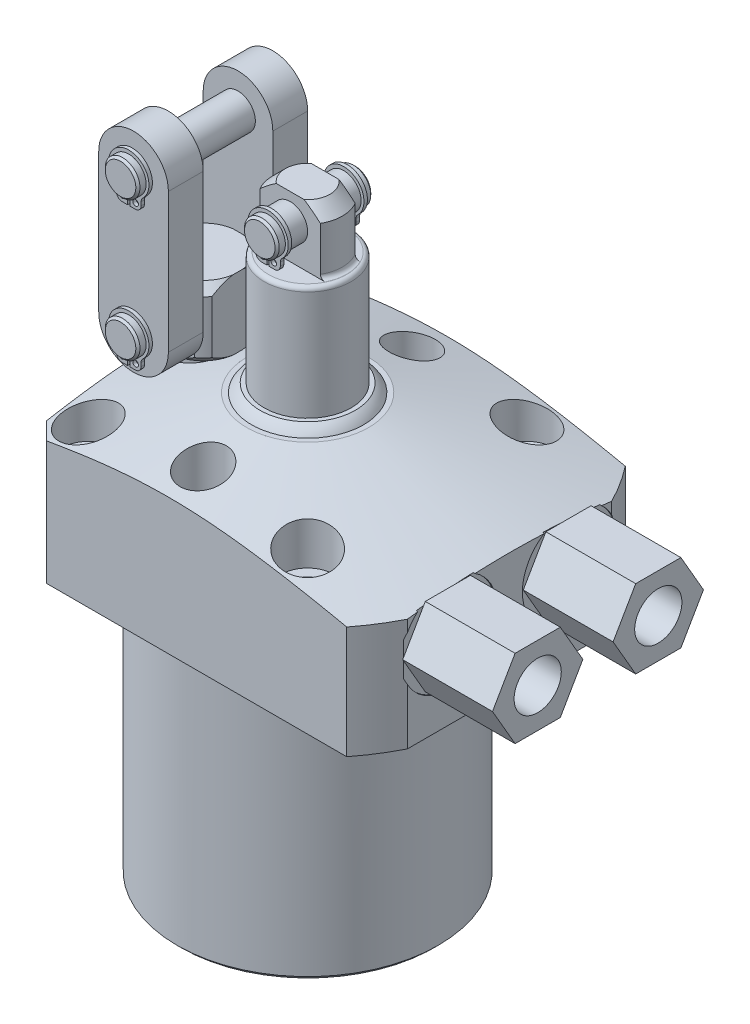
from build123d import *

# Parameters (mm, degrees)
SKETCH3_OUTSIDE_W          = 112.432
SKETCH3_OUTSIDE_H          = 112.432
SKETCH3_OUTSIDE_W_2        = 62.23
SKETCH3_OUTSIDE_H_2        = 50.8
CUT_EXTRUDE9_DEPTH         = 76.2
CHAMFER8_SIZE              = 3.175
CHAMFER5_SIZE              = 0.762
HOLE1_D                    = 5.5626
HOLE1_DEPTH                = 28.575
HOLE1_CBORE_D              = 9.525
HOLE1_CBORE_DEPTH          = 11.0998
SKETCH34_R                 = 4.2164
CUT_EXTRUDE10_DEPTH        = 12.7
EXTRUDE14_DEPTH            = 16.383
HOLE2_D                    = 8.6106
HOLE2_DEPTH                = 6.7056
SKETCH33_R                 = 0.889
CUT_EXTRUDE7_DEPTH         = 11.0998
FILLET4_R                  = 0.762
SKETCH29_R                 = 3.16865
EXTRUDE11_DEPTH            = 8.7249
EXTRUDE2_START             = -1.4986
SKETCH16_R                 = 0.5207
EXTRUDE2_DEPTH             = 0.635
CHAMFER6_SIZE              = 0.381
CUT_EXTRUDE11_DEPTH        = 12.7
SKETCH30_R                 = 3.16865
EXTRUDE12_DEPTH            = 15.0749
EXTRUDE4_START             = -1.4986
SKETCH19_R                 = 0.5207
EXTRUDE4_DEPTH             = 0.635
EXTRUDE13_DEPTH            = 6.35
CHAMFER7_SIZE              = 0.381
LPATTERN2_COUNT            = 2
LPATTERN2_PITCH            = 25.4
LPATTERN2_START            = -1.4986
LPATTERN2_COPY_1_SKETCH_R  = 0.5207
LPATTERN2_COPY_1_DEPTH     = 0.635
CHAMFER7_OF_LPATTERN2_SIZE = 0.381


with BuildPart() as part:
    # Sketch28 → Revolve7 (revolve)
    with BuildSketch(Plane.XY, mode=Mode.PRIVATE) as revolve7_sk:
        Polygon((-11.1125, 28.575), (-41.275, 20.492982483), (-41.275, 0), (-23.8125, 0), (-23.8125, -47.625), (0, -47.625), (0, 28.575), align=None)
    revolve(revolve7_sk.sketch.rotate(Axis((0, 0, 0), (0, 1, 0)), 270), axis=Axis((0, 0, 0), (0, 1, 0)))  # turned: the seam where the file's is

    # Sketch3 outside → Cut-Extrude9 (cut)
    with BuildSketch(Plane(origin=(0, 28.575, 0), x_dir=(-1, 0, 0), z_dir=(0, 1, 0))):
        Rectangle(SKETCH3_OUTSIDE_W, SKETCH3_OUTSIDE_H)
        with Locations((-5.715, 0)):
            Rectangle(SKETCH3_OUTSIDE_W_2, SKETCH3_OUTSIDE_H_2, mode=Mode.SUBTRACT)
    extrude(amount=-CUT_EXTRUDE9_DEPTH, mode=Mode.SUBTRACT)

    # Chamfer8
    chamfer8_edges = [part.edges().sort_by_distance(p)[0] for p in [
        (-25.4, 10.96378795, -25.4),
        (-25.4, 10.96378795, 25.4),
    ]]
    chamfer(chamfer8_edges, length=CHAMFER8_SIZE)

    # Chamfer5
    chamfer5_edges = [part.edges().sort_by_distance(p)[0] for p in [
        (0, -47.625, 23.8125),
    ]]
    chamfer(chamfer5_edges, length=CHAMFER5_SIZE)

    # Hole1
    with Locations(Plane(origin=(0, 28.575, 0), x_dir=(-1, 0, 0), z_dir=(0, 1, 0))):
        with Locations((-20.0025, -20.0025), (-20.0025, 20.0025), (20.0025, -20.0025), (20.0025, 20.0025)):
            CounterBoreHole(HOLE1_D / 2, HOLE1_CBORE_D / 2, HOLE1_CBORE_DEPTH, depth=HOLE1_DEPTH)

    # Sketch34 → Cut-Extrude10 (cut)
    with BuildSketch(Plane(origin=(0, 28.575, 0), x_dir=(1, 0, 0), z_dir=(0, 1, 0))):
        with Locations(Location((0, 19.05, 0), (0, 0, 270))):  # turned: the seam where the file's is
            Circle(SKETCH34_R)
        with Locations(Location((0, -19.05, 0), (0, 0, 133.869906741))):  # turned: the seam where the file's is
            Circle(SKETCH34_R)
        with Locations(Location((-19.05, 0, 0), (0, 0, 270))):  # turned: the seam where the file's is
            Circle(SKETCH34_R)
    extrude(amount=-CUT_EXTRUDE10_DEPTH, mode=Mode.SUBTRACT)

    # S2D0007 → Cut-Revolve2 (revolve, cut)
    with BuildSketch(Plane.XZ.offset(-14.2748)):
        Polygon((36.83, -10.9982), (36.83, -19.6596), (36.576, -19.6596), (36.576, -15.57655), (34.5059, -15.136536662), (33.821963338, -14.4526), (24.384, -14.4526), (22.308387078, -10.9982), align=None)
    cut_revolve2 = revolve(axis=Axis((-11.746808274, 14.2748, -10.9982), (-1, 0, 0)), mode=Mode.SUBTRACT)

    # Sketch6 → Cut-Revolve3 (revolve, cut)
    with BuildSketch(Plane.XY.offset(-10.9982), mode=Mode.PRIVATE) as cut_revolve3_sk:
        with BuildLine():
            Line((35.66795, 0), (35.66795, 1.4478))
            Line((35.66795, 1.4478), (32.60745581, 1.4478))
            ThreePointArc((32.60745581, 1.4478), (31.925854622, 0.917608896), (31.1404, 0.5588))
            Line((31.1404, 0.5588), (29.9974, 0.5588))
            Line((29.9974, 0.5588), (29.9974, 0))
            Line((29.9974, 0), (35.66795, 0))
        make_face()
    cut_revolve3 = revolve(cut_revolve3_sk.sketch.rotate(Axis((29.9974, -21.049171587, -10.9982), (0, 1, 0)), 90), axis=Axis((29.9974, -21.049171587, -10.9982), (0, 1, 0)), mode=Mode.SUBTRACT)  # turned: the seam where the file's is

    # Sketch39 → Extrude14 (add)
    with BuildSketch(Plane(origin=(36.576, 0, 0), x_dir=(0, 0, -1), z_dir=(1, 0, 0))):
        Polygon((19.239759623, 14.2748), (15.118979811, 21.4122), (6.877420189, 21.4122), (2.756640377, 14.2748), (6.877420189, 7.1374), (15.118979811, 7.1374), align=None)
    extrude14 = extrude(amount=EXTRUDE14_DEPTH)

    # Hole2
    with Locations(Plane(origin=(52.959, 0, 0), x_dir=(0, 0, -1), z_dir=(1, 0, 0))):
        with Locations((10.9982, 14.2748)):
            hole2 = Hole(HOLE2_D / 2, depth=HOLE2_DEPTH)

    # Mirror6: Cut-Revolve2, Cut-Revolve3, Extrude14, Hole2 across plane
    add(cut_revolve2.mirror(Plane.XY), mode=Mode.SUBTRACT)
    add(cut_revolve3.mirror(Plane.XY), mode=Mode.SUBTRACT)
    add(extrude14.mirror(Plane.XY))
    add(hole2.mirror(Plane.XY), mode=Mode.SUBTRACT)

    # Sketch12 → Revolve2 (revolve)
    with BuildSketch(Plane(origin=(0, 0, 0), x_dir=(-1, 0, 0), z_dir=(0, 0, -1)), mode=Mode.PRIVATE) as revolve2_sk:
        with BuildLine():
            Line((0, 28.575), (0, 30.099))
            Line((0, 30.099), (8.6995, 30.099))
            ThreePointArc((8.6995, 30.099), (9.549082922, 29.424582922), (10.2235, 28.575))
            Line((10.2235, 28.575), (0, 28.575))
        make_face()
    revolve(revolve2_sk.sketch.rotate(Axis((0, 22.10562, 0), (0, 1, 0)), 270), axis=Axis((0, 22.10562, 0), (0, 1, 0)))  # turned: the seam where the file's is

    # Sketch13 → Revolve3 (revolve)
    with BuildSketch(Plane.XY, mode=Mode.PRIVATE) as revolve3_sk:
        Polygon((0, 30.099), (0, 61.8998), (4.064, 61.8998), (6.35, 59.6138), (6.35, 50.8), (7.93115, 50.8), (7.93115, 30.099), align=None)
    revolve(revolve3_sk.sketch.rotate(Axis((0, 23.02637, 0), (0, 1, 0)), 90), axis=Axis((0, 23.02637, 0), (0, 1, 0)))  # turned: the seam where the file's is

    # Sketch14 → Cut-Extrude7 (cut)
    with BuildSketch(Plane(origin=(0, 61.8998, 0), x_dir=(-1, 0, 0), z_dir=(0, 1, 0))):
        with BuildLine():
            Line((-5.499261314, 3.175), (5.499261314, 3.175))
            ThreePointArc((5.499261314, 3.175), (0, 6.35), (-5.499261314, 3.175))
        make_face()
        with BuildLine():
            Line((5.499261314, -3.175), (-5.499261314, -3.175))
            ThreePointArc((-5.499261314, -3.175), (0, -6.35), (5.499261314, -3.175))
        make_face()
    extrude(amount=-CUT_EXTRUDE7_DEPTH, mode=Mode.SUBTRACT)

    # Fillet4
    fillet4_edges = [part.edges().sort_by_distance(p)[0] for p in [
        (0, 50.8, 7.93115),
        (-6.35, 50.8, 0),
        (6.35, 50.8, 0),
    ]]
    fillet(fillet4_edges, radius=FILLET4_R)

    # Sketch29 → Extrude11 (add, symmetric)
    with BuildSketch(Plane.XY):
        with Locations((0, 57.15)):
            Circle(SKETCH29_R)
    extrude(amount=EXTRUDE11_DEPTH, both=True)

    # Sketch16 → Extrude2 (add)
    with BuildSketch(Plane(origin=(0, 52.3748, 8.7249), x_dir=(1, 0, 0), z_dir=(0, 0, 1)).offset(EXTRUDE2_START)):
        with BuildLine():
            Line((0.20828, 1.861635097), (0.20828, -0.170364903))
            Line((0.20828, -0.170364903), (1.19888, -0.170364903))
            ThreePointArc((1.19888, -0.170364903), (1.935261002, 0.134654095), (2.24028, 0.871035097))
            Line((2.24028, 0.871035097), (2.24028, 1.503592677))
            ThreePointArc((2.24028, 1.503592677), (2.323076064, 1.910523204), (2.558298925, 2.252748054))
            ThreePointArc((2.558298925, 2.252748054), (0, 8.5852), (-2.558298925, 2.252748054))
            ThreePointArc((-2.558298925, 2.252748054), (-2.323076064, 1.910523204), (-2.24028, 1.503592677))
            Line((-2.24028, 1.503592677), (-2.24028, 0.871035097))
            ThreePointArc((-2.24028, 0.871035097), (-1.935261002, 0.134654095), (-1.19888, -0.170364903))
            Line((-1.19888, -0.170364903), (-0.20828, -0.170364903))
            Line((-0.20828, -0.170364903), (-0.20828, 1.861635097))
            ThreePointArc((-0.20828, 1.861635097), (0, 7.6962), (0.20828, 1.861635097))
        make_face()
        with Locations((1.0414, 0.871035097)):
            Circle(SKETCH16_R, mode=Mode.SUBTRACT)
        with Locations(Location((-1.0414, 0.871035097, 0), (0, 0, 180))):  # turned: the seam where the file's is
            Circle(SKETCH16_R, mode=Mode.SUBTRACT)
    extrude2 = extrude(amount=-EXTRUDE2_DEPTH)

    # Chamfer6
    chamfer6_edges = [part.edges().sort_by_distance(p)[0] for p in [
        (-3.16865, 57.15, -8.7249),
        (-3.16865, 57.15, 8.7249),
    ]]
    chamfer(chamfer6_edges, length=CHAMFER6_SIZE)

    # Mirror2: Extrude2 across plane
    add(extrude2.mirror(Plane.XY))

    # Sketch35 → Revolve10 (revolve)
    with BuildSketch(Plane.XY, mode=Mode.PRIVATE) as revolve10_sk:
        Polygon((-19.05, 15.875), (-14.2875, 15.875), (-14.2875, 28.575), (-12.6365, 28.575), (-11.1125, 30.099), (-11.1125, 39.751), (-12.6365, 41.275), (-19.05, 41.275), align=None)
    revolve(revolve10_sk.sketch.rotate(Axis((-19.05, 43.57409058, 0), (0, -1, 0)), 180), axis=Axis((-19.05, 43.57409058, 0), (0, -1, 0)))  # turned: the seam where the file's is

    # Sketch36 → Cut-Extrude11 (cut)
    with BuildSketch(Plane(origin=(0, 41.275, 0), x_dir=(1, 0, 0), z_dir=(0, 1, 0))):
        with BuildLine():
            Line((-23.8125, 6.35), (-14.2875, 6.35))
            ThreePointArc((-14.2875, 6.35), (-19.05, 7.9375), (-23.8125, 6.35))
        make_face()
        with BuildLine():
            Line((-25.4, 4.7625), (-25.4, -4.7625))
            ThreePointArc((-25.4, -4.7625), (-26.9875, 0), (-25.4, 4.7625))
        make_face()
        with BuildLine():
            Line((-23.8125, -6.35), (-14.2875, -6.35))
            ThreePointArc((-14.2875, -6.35), (-19.05, -7.9375), (-23.8125, -6.35))
        make_face()
        with BuildLine():
            Line((-12.7, 4.7625), (-12.7, -4.7625))
            ThreePointArc((-12.7, -4.7625), (-11.1125, 0), (-12.7, 4.7625))
        make_face()
    extrude(amount=-CUT_EXTRUDE11_DEPTH, mode=Mode.SUBTRACT)

    # Sketch30 → Extrude12 (add, symmetric)
    with BuildSketch(Plane.XY):
        with Locations((-19.05, 34.925)):
            Circle(SKETCH30_R)
    extrude12 = extrude(amount=EXTRUDE12_DEPTH, both=True)

    # Sketch19 → Extrude4 (add)
    with BuildSketch(Plane(origin=(-22.225, 11.0998, 15.0749), x_dir=(1, 0, 0), z_dir=(0, 0, 1)).offset(EXTRUDE4_START)):
        with BuildLine():
            Line((3.38328, 20.911635097), (3.38328, 18.879635097))
            Line((3.38328, 18.879635097), (4.37388, 18.879635097))
            ThreePointArc((4.37388, 18.879635097), (5.110261002, 19.184654095), (5.41528, 19.921035097))
            Line((5.41528, 19.921035097), (5.41528, 20.553592677))
            ThreePointArc((5.41528, 20.553592677), (5.498076064, 20.960523204), (5.733298925, 21.302748054))
            ThreePointArc((5.733298925, 21.302748054), (3.175, 27.6352), (0.616701075, 21.302748054))
            ThreePointArc((0.616701075, 21.302748054), (0.851923936, 20.960523204), (0.93472, 20.553592677))
            Line((0.93472, 20.553592677), (0.93472, 19.921035097))
            ThreePointArc((0.93472, 19.921035097), (1.239738998, 19.184654095), (1.97612, 18.879635097))
            Line((1.97612, 18.879635097), (2.96672, 18.879635097))
            Line((2.96672, 18.879635097), (2.96672, 20.911635097))
            ThreePointArc((2.96672, 20.911635097), (3.175, 26.7462), (3.38328, 20.911635097))
        make_face()
        with Locations((4.42468, 19.921035097)):
            Circle(SKETCH19_R, mode=Mode.SUBTRACT)
        with Locations(Location((1.92532, 19.921035097, 0), (0, 0, 180))):  # turned: the seam where the file's is
            Circle(SKETCH19_R, mode=Mode.SUBTRACT)
    extrude4 = extrude(amount=-EXTRUDE4_DEPTH)

    # Sketch37 → Extrude13 (add)
    with BuildSketch(Plane.XY.offset(6.35)):
        with BuildLine():
            Line((-25.400000096, 60.324999976), (-25.4, 34.924999976))
            ThreePointArc((-25.4, 34.924999976), (-19.049999976, 28.575), (-12.7, 34.925000024))
            Line((-12.7, 34.925000024), (-12.700000096, 60.325000024))
            ThreePointArc((-12.700000096, 60.325000024), (-19.05000012, 66.675), (-25.400000096, 60.324999976))
        make_face()
    extrude13 = extrude(amount=EXTRUDE13_DEPTH)

    # Mirror3: Extrude4 across plane
    add(extrude4.mirror(Plane.XY))

    # Chamfer7
    chamfer7_edges = [part.edges().sort_by_distance(p)[0] for p in [
        (-22.21865, 34.925, -15.0749),
        (-22.21865, 34.925, 15.0749),
    ]]
    chamfer(chamfer7_edges, length=CHAMFER7_SIZE)

    # LPattern2: Extrude4, Extrude12 ×2
    with Locations(*[(0, i * LPATTERN2_PITCH, 0) for i in range(1, LPATTERN2_COUNT)]):
        add(extrude4)
        add(extrude12)

    # LPattern2 copy 1 sketch → LPattern2 copy 1 (add)
    with BuildSketch(Plane(origin=(-22.225000096, 36.4998, -15.0749), x_dir=(1, 0, 0), z_dir=(0, 0, -1)).offset(LPATTERN2_START)):
        with BuildLine():
            Line((3.38328, -20.911635097), (3.38328, -18.879635097))
            Line((3.38328, -18.879635097), (4.37388, -18.879635097))
            ThreePointArc((4.37388, -18.879635097), (5.110261002, -19.184654095), (5.41528, -19.921035097))
            Line((5.41528, -19.921035097), (5.41528, -20.553592677))
            ThreePointArc((5.41528, -20.553592677), (5.498076064, -20.960523204), (5.733298925, -21.302748054))
            ThreePointArc((5.733298925, -21.302748054), (3.175, -27.6352), (0.616701075, -21.302748054))
            ThreePointArc((0.616701075, -21.302748054), (0.851923936, -20.960523204), (0.93472, -20.553592677))
            Line((0.93472, -20.553592677), (0.93472, -19.921035097))
            ThreePointArc((0.93472, -19.921035097), (1.239738998, -19.184654095), (1.97612, -18.879635097))
            Line((1.97612, -18.879635097), (2.96672, -18.879635097))
            Line((2.96672, -18.879635097), (2.96672, -20.911635097))
            ThreePointArc((2.96672, -20.911635097), (3.175, -26.7462), (3.38328, -20.911635097))
        make_face()
        with Locations((4.42468, -19.921035097)):
            Circle(LPATTERN2_COPY_1_SKETCH_R, mode=Mode.SUBTRACT)
        with Locations((1.92532, -19.921035097)):
            Circle(LPATTERN2_COPY_1_SKETCH_R, mode=Mode.SUBTRACT)
    extrude(amount=-LPATTERN2_COPY_1_DEPTH)

    # Chamfer7 of LPattern2
    chamfer7_of_lpattern2_edges = [part.edges().sort_by_distance(p)[0] for p in [
        (-22.218650096, 60.325, -15.0749),
        (-22.218650096, 60.325, 15.0749),
    ]]
    chamfer(chamfer7_of_lpattern2_edges, length=CHAMFER7_OF_LPATTERN2_SIZE)

    # Mirror8: Extrude13 across plane
    add(extrude13.mirror(Plane.XY))


with BuildPart() as body_2:
    # Sketch33 → Revolve9 (revolve)
    with BuildSketch(Plane.XY.offset(-10.9982), mode=Mode.PRIVATE) as revolve9_sk:
        with Locations((25.21585, 0.5842)):
            Circle(SKETCH33_R)
    revolve(revolve9_sk.sketch.rotate(Axis((29.9974, 8.329668034, -10.9982), (0, -1, 0)), 90), axis=Axis((29.9974, 8.329668034, -10.9982), (0, -1, 0)))  # turned: the seam where the file's is


with BuildPart() as body_3:
    # Mirror7: mirrored copy
    add(body_2.part.mirror(Plane.XY))


solid = Compound([part.part, body_2.part, body_3.part])
